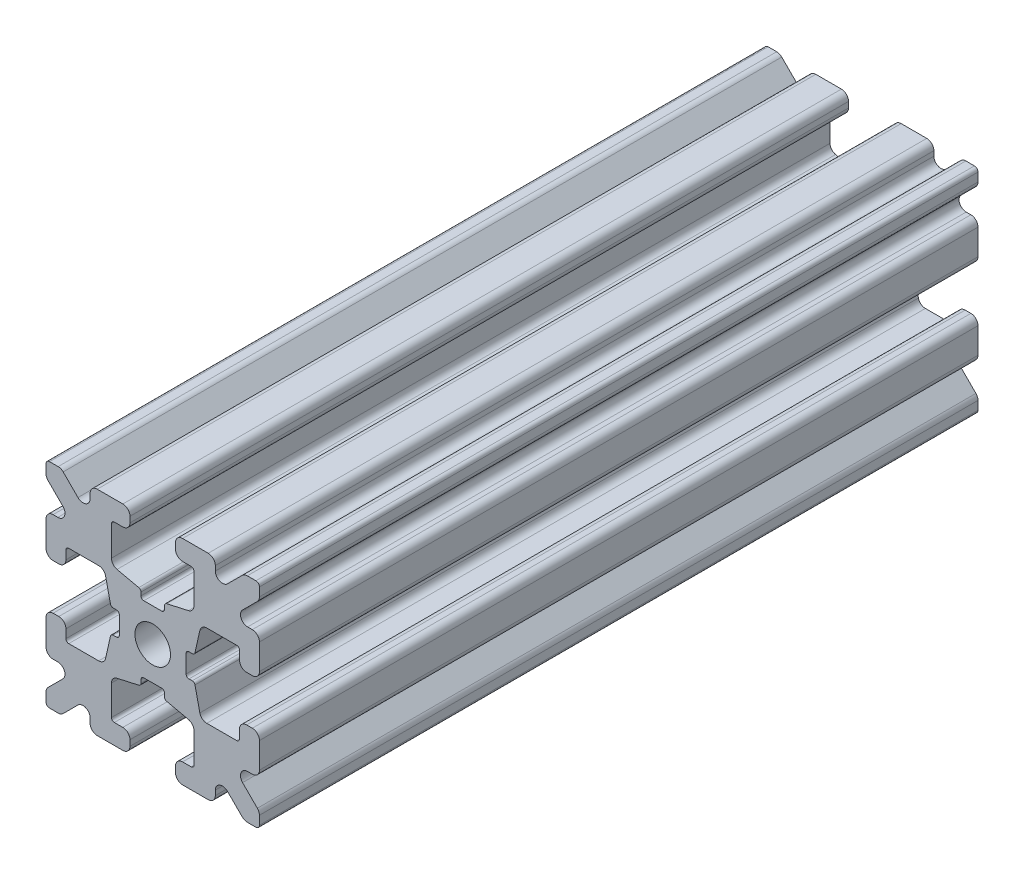
from build123d import *

# Parameters (mm, degrees)
SKETCH1_W           = 15
SKETCH1_H           = 15
SKETCH1_R           = 1.25
BOSS_EXTRUDE1_DEPTH = 25.25
FILLET1_R           = 0.25
CUT_EXTRUDE1_DEPTH  = 51.5
CUT_EXTRUDE3_DEPTH  = 51.5
FILLET3_R           = 0.5
FILLET4_R           = 0.5
FILLET5_R           = 3
FILLET6_R           = 0.2
CUT_EXTRUDE4_DEPTH  = 51.5
FILLET8_R           = 0.5
SKETCH6_W           = 5.1529354
SKETCH6_H           = 1.651
SKETCH6_W_2         = 1.651
SKETCH6_H_2         = 5.1529354
CUT_EXTRUDE5_DEPTH  = 51.5
FILLET10_R          = 0.2


with BuildPart() as part:
    # Sketch1 → Boss-Extrude1 (new body, symmetric)
    with BuildSketch(Plane.XY):
        Rectangle(SKETCH1_W, SKETCH1_H)
        Circle(SKETCH1_R, mode=Mode.SUBTRACT)
    extrude(amount=BOSS_EXTRUDE1_DEPTH, both=True)

    # Fillet1
    fillet1_edges = [part.edges().sort_by_distance(p)[0] for p in [
        (7.5, -7.5, 0),
        (-7.5, -7.5, 0),
        (-7.5, 7.5, 0),
        (7.5, 7.5, 0),
    ]]
    fillet(fillet1_edges, radius=FILLET1_R)

    # Sketch2 → Cut-Extrude1 (cut, through all)
    with BuildSketch(Plane.XY.offset(25.25)):
        Polygon((-7.5, 1.6), (-6.1, 1.6), (-6.1, 2.9), (-3.4, 2.9), (-3.4, -2.9), (-6.1, -2.9), (-6.1, -1.6), (-7.5, -1.6), align=None)
        Polygon((2.9, 6.1), (1.6, 6.1), (1.6, 7.5), (-1.6, 7.5), (-1.6, 6.1), (-2.9, 6.1), (-2.9, 3.4), (2.9, 3.4), align=None)
        Polygon((-1.6, -7.5), (-1.6, -6.1), (-2.9, -6.1), (-2.9, -3.4), (2.9, -3.4), (2.9, -6.1), (1.6, -6.1), (1.6, -7.5), align=None)
        Polygon((6.1, -2.9), (6.1, -1.6), (7.5, -1.6), (7.5, 1.6), (6.1, 1.6), (6.1, 2.9), (3.4, 2.9), (3.4, -2.9), align=None)
    extrude(amount=-CUT_EXTRUDE1_DEPTH, mode=Mode.SUBTRACT)

    # Sketch4 → Cut-Extrude3 (cut, through all)
    with BuildSketch(Plane.XY.offset(25.25)):
        Polygon((-3.4, 2.9), (-2.75, 0), (-3.4, -2.9), align=None)
        Polygon((-2.9, 3.4), (0, 2.75), (2.9, 3.4), align=None)
        Polygon((3.4, 2.9), (2.75, 0), (3.4, -2.9), align=None)
        Polygon((-2.9, -3.4), (0, -2.75), (2.9, -3.4), align=None)
    extrude(amount=-CUT_EXTRUDE3_DEPTH, mode=Mode.SUBTRACT)

    # Fillet3
    fillet3_edges = [part.edges().sort_by_distance(p)[0] for p in [
        (1.6, -7.5, 0),
        (-1.6, -7.5, 0),
        (-1.6, -6.1, 0),
        (1.6, -6.1, 0),
        (6.1, 1.6, 0),
        (7.5, 1.6, 0),
        (7.5, -1.6, 0),
        (6.1, -1.6, 0),
        (-7.5, -1.6, 0),
        (-7.5, 1.6, 0),
        (-6.1, 1.6, 0),
        (-6.1, -1.6, 0),
        (-1.6, 6.1, 0),
        (-1.6, 7.5, 0),
        (1.6, 7.5, 0),
        (1.6, 6.1, 0),
    ]]
    fillet(fillet3_edges, radius=FILLET3_R)

    # Fillet4
    fillet4_edges = [part.edges().sort_by_distance(p)[0] for p in [
        (-2.9, -3.4, 0),
        (2.9, -3.4, 0),
        (3.4, -2.9, 0),
        (3.4, 2.9, 0),
        (-3.4, 2.9, 0),
        (-3.4, -2.9, 0),
        (2.9, 3.4, 0),
        (-2.9, 3.4, 0),
    ]]
    fillet(fillet4_edges, radius=FILLET4_R)

    # Fillet5
    fillet5_edges = [part.edges().sort_by_distance(p)[0] for p in [
        (-2.75, 0, 0),
        (0, 2.75, 0),
        (2.75, 0, 0),
        (0, -2.75, 0),
    ]]
    fillet(fillet5_edges, radius=FILLET5_R)

    # Fillet6
    fillet6_edges = [part.edges().sort_by_distance(p)[0] for p in [
        (-2.9, -6.1, 0),
        (2.9, -6.1, 0),
        (6.1, -2.9, 0),
        (6.1, 2.9, 0),
        (-6.1, 2.9, 0),
        (-6.1, -2.9, 0),
        (2.9, 6.1, 0),
        (-2.9, 6.1, 0),
    ]]
    fillet(fillet6_edges, radius=FILLET6_R)

    # Sketch5 → Cut-Extrude4 (cut, through all)
    with BuildSketch(Plane.XY.offset(25.25)):
        Polygon((-7.5, 6.439339828), (-5.460660172, 4.4), (-7.5, 4.4), align=None)
        Polygon((-6.439339828, 7.5), (-4.4, 5.460660172), (-4.4, 7.5), align=None)
        Polygon((4.4, 7.5), (6.439339828, 7.5), (4.4, 5.460660172), align=None)
        Polygon((7.5, 6.439339828), (7.5, 4.4), (5.460660172, 4.4), align=None)
        Polygon((7.5, -6.439339828), (5.460660172, -4.4), (7.5, -4.4), align=None)
        Polygon((6.439339828, -7.5), (4.4, -5.460660172), (4.4, -7.5), align=None)
        Polygon((-4.4, -7.5), (-6.439339828, -7.5), (-4.4, -5.460660172), align=None)
        Polygon((-7.5, -6.439339828), (-7.5, -4.4), (-5.460660172, -4.4), align=None)
    extrude(amount=-CUT_EXTRUDE4_DEPTH, mode=Mode.SUBTRACT)

    # Fillet8
    fillet8_edges = [part.edges().sort_by_distance(p)[0] for p in [
        (-7.5, 4.4, 0),
        (-7.5, 6.439339828, 0),
        (-5.460660172, 4.4, 0),
        (7.5, -4.4, 0),
        (7.5, -6.439339828, 0),
        (5.460660172, -4.4, 0),
        (5.460660172, 4.4, 0),
        (7.5, 6.439339828, 0),
        (7.5, 4.4, 0),
        (-4.4, 7.5, 0),
        (-4.4, 5.460660172, 0),
        (-6.439339828, 7.5, 0),
        (-5.460660172, -4.4, 0),
        (-7.5, -6.439339828, 0),
        (-7.5, -4.4, 0),
        (4.4, 5.460660172, 0),
        (4.4, 7.5, 0),
        (6.439339828, 7.5, 0),
        (6.439339828, -7.5, 0),
        (4.4, -7.5, 0),
        (4.4, -5.460660172, 0),
        (-6.439339828, -7.5, 0),
        (-4.4, -5.460660172, 0),
        (-4.4, -7.5, 0),
    ]]
    fillet(fillet8_edges, radius=FILLET8_R)

    # Sketch6 → Cut-Extrude5 (cut, through all)
    with BuildSketch(Plane.XY.offset(25.25)):
        with Locations((4.9235323, 0)):
            Rectangle(SKETCH6_W, SKETCH6_H)
        with Locations((0, -4.9235323)):
            Rectangle(SKETCH6_W_2, SKETCH6_H_2)
        with Locations((-4.9235323, 0)):
            Rectangle(SKETCH6_W, SKETCH6_H)
        with Locations((0, 4.9235323)):
            Rectangle(SKETCH6_W_2, SKETCH6_H_2)
    extrude(amount=-CUT_EXTRUDE5_DEPTH, mode=Mode.SUBTRACT)

    # Fillet10
    fillet10_edges = [part.edges().sort_by_distance(p)[0] for p in [
        (0.8255, -2.935025862, 0),
        (-0.8255, -2.935025862, 0),
        (0.8255, -2.3470646, 0),
        (-0.8255, -2.3470646, 0),
        (2.935025862, 0.8255, 0),
        (2.935025862, -0.8255, 0),
        (2.3470646, 0.8255, 0),
        (2.3470646, -0.8255, 0),
        (-2.935025862, -0.8255, 0),
        (-2.935025862, 0.8255, 0),
        (-2.3470646, -0.8255, 0),
        (-2.3470646, 0.8255, 0),
        (-0.8255, 2.935025862, 0),
        (0.8255, 2.935025862, 0),
        (-0.8255, 2.3470646, 0),
        (0.8255, 2.3470646, 0),
    ]]
    fillet(fillet10_edges, radius=FILLET10_R)


solid = part.part
